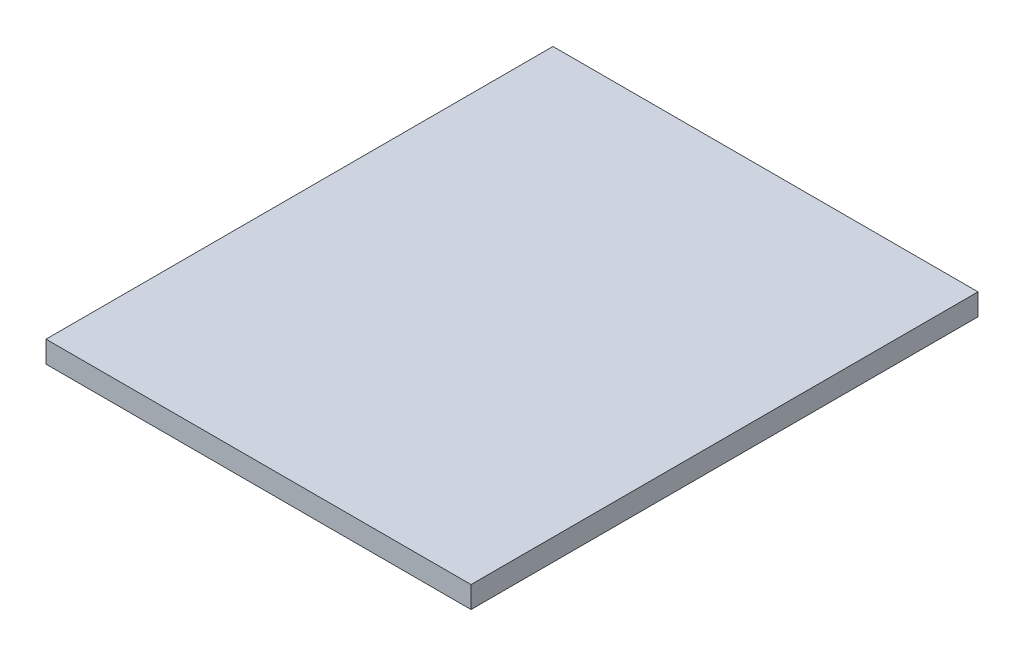
from build123d import *

# Parameters (mm, degrees)
SKETCH1_W           = 30.6
SKETCH1_H           = 36.5
BOSS_EXTRUDE1_DEPTH = 1.56


with BuildPart() as part:
    # Sketch1 → Boss-Extrude1 (new body)
    with BuildSketch(Plane(origin=(0, 0, 0), x_dir=(1, 0, 0), z_dir=(0, 1, 0))):
        with Locations((15.3, 18.25)):
            Rectangle(SKETCH1_W, SKETCH1_H)
    extrude(amount=BOSS_EXTRUDE1_DEPTH)


solid = part.part
